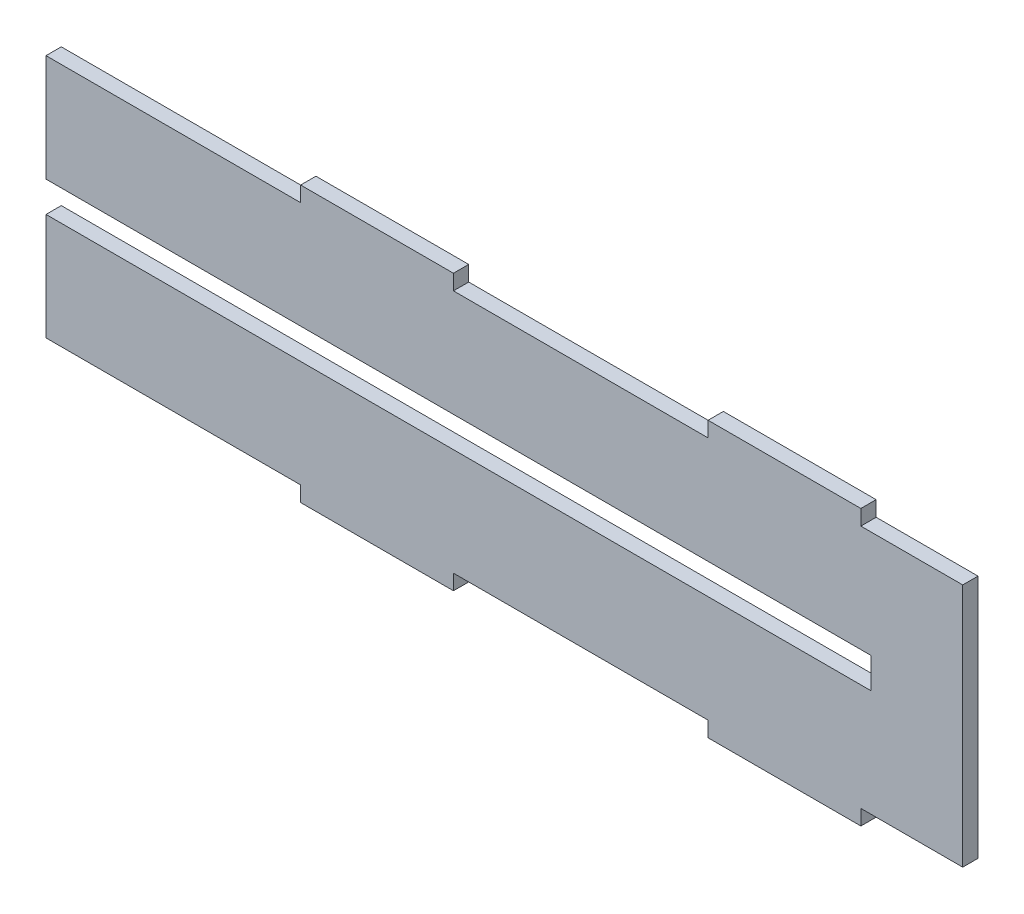
from build123d import *

# Parameters (mm, degrees)
RESSALTO_EXTRUS_O1_DEPTH = 3


with BuildPart() as part:
    # Esboço1 → Ressalto-extrusão1 (new body)
    with BuildSketch(Plane.XY):
        Polygon((0, -27), (0, -48), (50, -48), (50, -51), (80, -51), (80, -48), (130, -48), (130, -51), (160, -51), (160, -48), (180, -48), (180, 0), (160, 0), (160, 3), (130, 3), (130, 0), (80, 0), (80, 3), (50, 3), (50, 0), (0, 0), (0, -21), (162, -21), (162, -27), align=None)
    extrude(amount=RESSALTO_EXTRUS_O1_DEPTH)


solid = part.part
